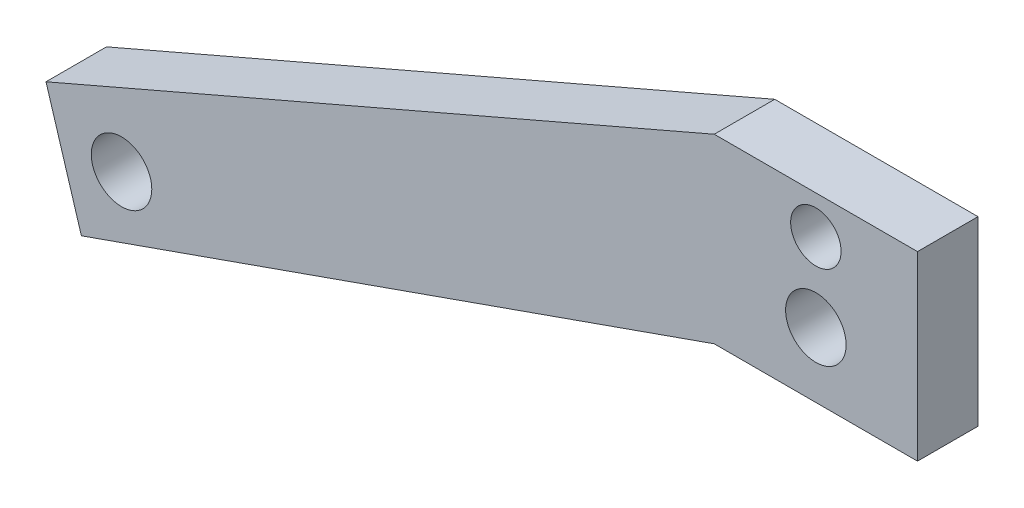
from build123d import *

# Parameters (mm, degrees)
SKETCH1_R           = 3.96875
SKETCH1_R_2         = 4.762500002
BOSS_EXTRUDE1_DEPTH = 9.525


with BuildPart() as part:
    # Sketch1 → Boss-Extrude1 (new body)
    with BuildSketch(Plane.XY):
        Polygon((-15.999993773, 44.99997758), (-121.199270656, -0.446548924), (-115.629589681, -18.664154525), (-15.999993773, 16.42497758), (16.000006227, 16.42497758), (16.000006227, 44.99997758), align=None)
        with Locations((6.227e-06, 38.99997758)):
            Circle(SKETCH1_R, mode=Mode.SUBTRACT)
        with Locations((6.239e-06, 26.647574613)):
            Circle(SKETCH1_R_2, mode=Mode.SUBTRACT)
        with Locations((-109.305627368, -6.770511237)):
            Circle(SKETCH1_R_2, mode=Mode.SUBTRACT)
    extrude(amount=BOSS_EXTRUDE1_DEPTH)


solid = part.part
